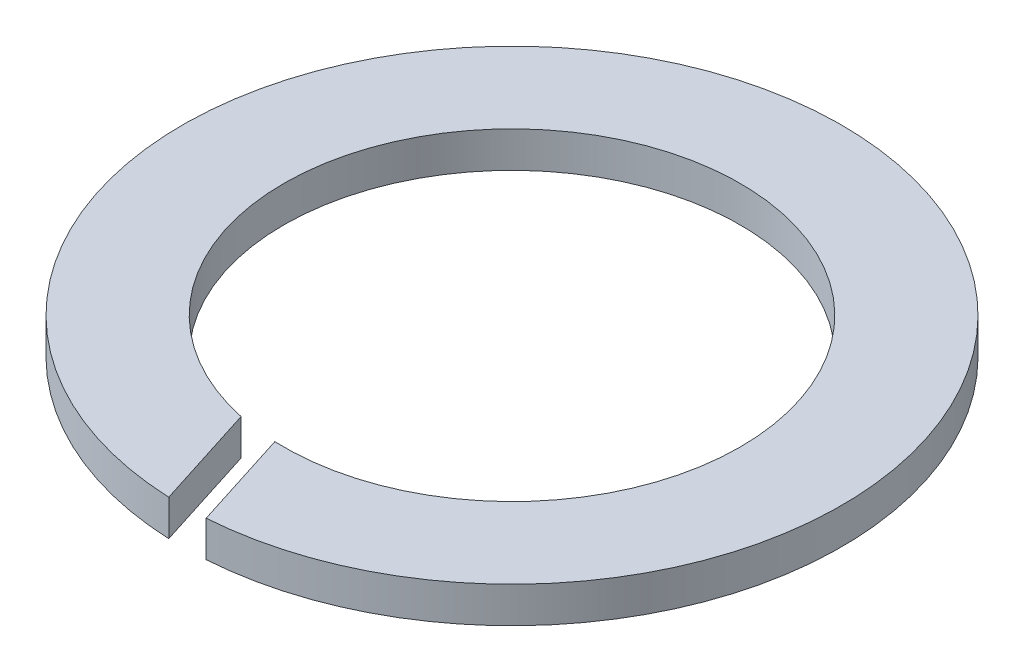
from build123d import *

# Parameters (mm, degrees)
CROQUIS1_R              = 27.5
CROQUIS1_R_2            = 19.05
SALIENTE_EXTRUIR1_DEPTH = 3
CORTAR_EXTRUIR1_DEPTH   = 3


with BuildPart() as part:
    # Croquis1 → Saliente-Extruir1 (new body)
    with BuildSketch(Plane(origin=(0, 0, 0), x_dir=(1, 0, 0), z_dir=(0, 1, 0))):
        Circle(CROQUIS1_R)
        Circle(CROQUIS1_R_2, mode=Mode.SUBTRACT)
    extrude(amount=SALIENTE_EXTRUIR1_DEPTH)

    # Croquis2 → Cortar-Extruir1 (cut)
    with BuildSketch(Plane(origin=(0, 3, 0), x_dir=(1, 0, 0), z_dir=(0, 1, 0))):
        Polygon((-1.170833669, -27.475064122), (-3.980970396, -18.629395447), (-1.170833669, -17.73665701), (2.334832716, -28.771694214), (-0.475304011, -29.664432651), align=None)
    extrude(amount=-CORTAR_EXTRUIR1_DEPTH, mode=Mode.SUBTRACT)


solid = part.part
